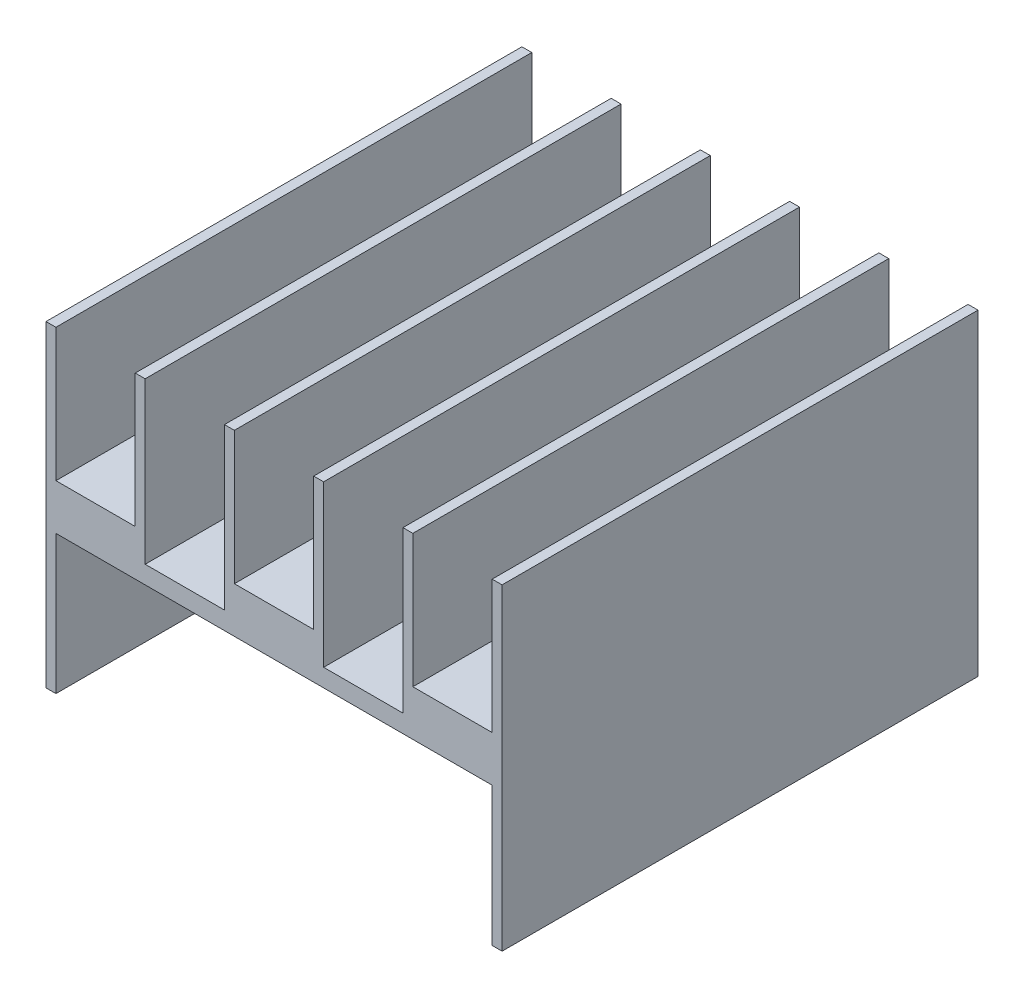
from build123d import *
from build123d.topology import SkipClean

# Parameters (mm, degrees)
BOSS_EXTRUDE1_DEPTH = 24
SKETCH2_R           = 1.5
CUT_EXTRUDE1_DEPTH  = 4
THREAD1_PITCH       = 0.25
THREAD1_HEIGHT      = 2.3
THREAD1_RADIUS      = 1.5
THREAD1_START_ANGLE = 90


with BuildPart() as part:
    # Sketch1 → Boss-Extrude1 (new body)
    with BuildSketch(Plane.XY):
        Polygon((-11, -8), (-11.5, -8), (-11.5, 8), (-11, 8), (-11, 1.3), (-7, 1.3), (-7, 8), (-6.5, 8), (-6.5, -0.1), (-2.5, -0.1), (-2.5, 8), (-2, 8), (-2, 1.3), (2, 1.3), (2, 8), (2.5, 8), (2.5, -0.1), (6.5, -0.1), (6.5, 8), (7, 8), (7, 1.3), (11, 1.3), (11, 8), (11.5, 8), (11.5, -8), (11, -8), (11, -1), (-11, -1), align=None)
    extrude(amount=BOSS_EXTRUDE1_DEPTH)

    # Sketch2 → Cut-Extrude1 (cut)
    with BuildSketch(Plane.XZ.offset(1)):
        with Locations(Location((0, 6, 0), (0, 0, 270))):
            Circle(SKETCH2_R)
    extrude(amount=-CUT_EXTRUDE1_DEPTH, mode=Mode.SUBTRACT)

    # Thread1: sweep along a helix
    with SkipClean():  # the faces are left unmerged after this step: merging them gives an invalid solid
        with BuildLine() as thread1_path:
            add(Helix(THREAD1_PITCH, THREAD1_HEIGHT, THREAD1_RADIUS, center=(0, -1, 6), direction=(0, 1, 0), mode=Mode.PRIVATE).rotate(Axis((0, -1, 6), (0, 1, 0)), THREAD1_START_ANGLE))
        # Thread Profile1 → Thread1 (sweep, cut)
        with BuildSketch(Plane(origin=(1.5, -1, 6), x_dir=(1, 0, 0), z_dir=(0, 0, 1))):
            Polygon((0, 0), (0.135316469, 0.078125), (0.135316469, 0.109375), (0, 0.187499999), align=None)
        sweep(path=thread1_path.line, is_frenet=True, mode=Mode.SUBTRACT)


solid = part.part
